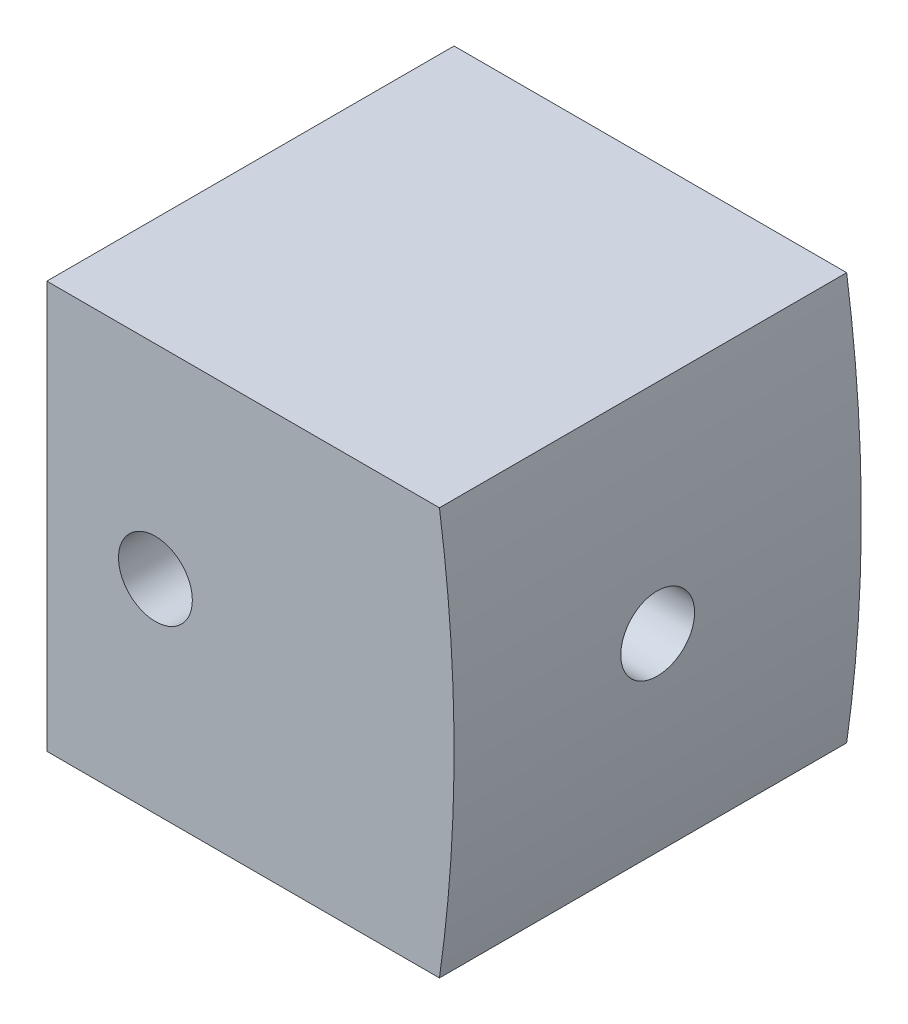
from build123d import *

# Parameters (mm, degrees)
SKETCH1_W                   = 19.05
SKETCH1_H                   = 19.05
EXTRUDE1_DEPTH              = 19.05
F_29_0_136_DIAMETER_HOLE1_D = 3.4544
EXTRUDE2_DEPTH              = 1
EXTRUDE2_DEPTH_BACK         = 20.05
F_29_0_136_DIAMETER_HOLE3_D = 3.4544


with BuildPart() as part:
    # Sketch1 → Extrude1 (new body)
    with BuildSketch(Plane.XY):
        Rectangle(SKETCH1_W, SKETCH1_H)
    extrude(amount=EXTRUDE1_DEPTH)

    # #29 (0.136) Diameter Hole1 (through all)
    with Locations(Plane.ZY.offset(9.525)):
        with Locations((9.525, 0)):
            Hole(F_29_0_136_DIAMETER_HOLE1_D / 2)

    # Sketch7 → Extrude2 (cut, two sides)
    with BuildSketch(Plane.XY.offset(19.05)) as extrude2_sk:
        with BuildLine():
            Line((9.525, -9.525), (9.525, 0))
            ThreePointArc((9.525, 0), (9.353814185, -4.774759033), (8.841135768, -9.525))
            Line((8.841135768, -9.525), (9.525, -9.525))
        make_face()
        with BuildLine():
            ThreePointArc((8.841135768, 9.525), (9.353814185, 4.774759033), (9.525, 0))
            Line((9.525, 0), (9.525, 9.525))
            Line((9.525, 9.525), (8.841135768, 9.525))
        make_face()
    extrude(amount=EXTRUDE2_DEPTH, mode=Mode.SUBTRACT)
    extrude(extrude2_sk.sketch, amount=-EXTRUDE2_DEPTH_BACK, mode=Mode.SUBTRACT)

    # #29 (0.136) Diameter Hole3 (through all)
    with Locations(Plane(origin=(-4.445, 0, 19.05), x_dir=(1, 0, 0), z_dir=(0, 0, 1))):
        with Locations((0, 0)):
            Hole(F_29_0_136_DIAMETER_HOLE3_D / 2)


solid = part.part
